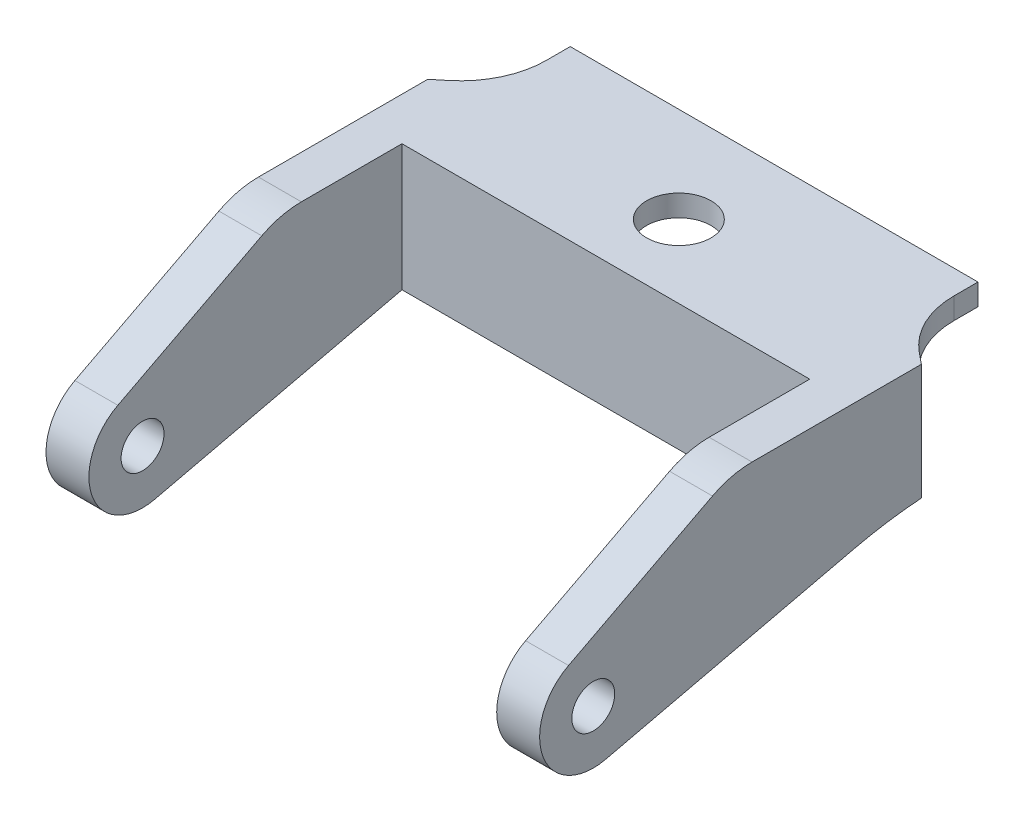
from build123d import *

# Parameters (mm, degrees)
EXTRUDE_1_DEPTH          = 20
EXTRUDE_1_DEPTH_BACK     = 5
EXTRUDE_2_DEPTH          = 5.5
SKETCH_1_5_R             = 1.5
CUT_EXTRUDE_1_DEPTH      = 4.5
CUT_EXTRUDE_1_DEPTH_BACK = 2
SKETCH_3_R               = 1
CUT_EXTRUDE_2_DEPTH      = 100
FILLET_3_R               = 20
FILLET_8_R               = 4


with BuildPart() as part:
    # 草图1 → 凸台-拉伸1 (new body, two sides)
    with BuildSketch(Plane(origin=(0, 0, 0), x_dir=(1, 0, 0), z_dir=(0, 1, 0))) as extrude_1_sk:
        with BuildLine():
            Line((0, -51.852813742), (0, -52.252813742))
            Line((0, -52.252813742), (9.5, -52.252813742))
            Line((9.5, -52.252813742), (9.5, -70.252813742))
            Line((9.5, -70.252813742), (11.5, -70.252813742))
            Line((11.5, -70.252813742), (11.5, -49.052813742))
            Line((11.5, -49.052813742), (9.5, -47.413831048))
            Line((9.5, -47.413831048), (9.5, -44.41312259))
            Line((9.5, -44.41312259), (0, -44.41312259))
            Line((0, -44.41312259), (0, -47.352813742))
            ThreePointArc((0, -47.352813742), (1.5, -48.852813742), (0, -50.352813742))
            Line((0, -50.352813742), (0, -51.852813742))
        make_face()
    extrude(amount=EXTRUDE_1_DEPTH)
    extrude(extrude_1_sk.sketch, amount=-EXTRUDE_1_DEPTH_BACK)

    # 草图1<7> → 凸台-拉伸2 (add)
    with BuildSketch(Plane(origin=(0, 0, 0), x_dir=(1, 0, 0), z_dir=(0, 1, 0))):
        with BuildLine():
            Line((0, -50.352813742), (0, -51.852813742))
            ThreePointArc((0, -51.852813742), (2.274628745, -50.808846481), (2.966165528, -48.403523125))
            Line((2.966165528, -48.403523125), (9.5, -47.413831048))
            Line((9.5, -47.413831048), (9.5, -44.41312259))
            Line((9.5, -44.41312259), (0, -44.41312259))
            Line((0, -44.41312259), (0, -47.352813742))
            ThreePointArc((0, -47.352813742), (1.5, -48.852813742), (0, -50.352813742))
        make_face()
    extrude(amount=EXTRUDE_2_DEPTH)

    # 草图1<5> → 切除-拉伸1 (cut, two sides)
    with BuildSketch(Plane(origin=(0, 0, 0), x_dir=(1, 0, 0), z_dir=(0, 1, 0))) as cut_extrude_1_sk:
        with BuildLine():
            Line((0, -50.352813742), (0, -51.852813742))
            ThreePointArc((0, -51.852813742), (2.274628745, -50.808846481), (2.966165528, -48.403523125))
            Line((2.966165528, -48.403523125), (9.5, -47.413831048))
            Line((9.5, -47.413831048), (9.5, -44.41312259))
            Line((9.5, -44.41312259), (0, -44.41312259))
            Line((0, -44.41312259), (0, -47.352813742))
            ThreePointArc((0, -47.352813742), (1.5, -48.852813742), (0, -50.352813742))
        make_face()
        with BuildLine():
            Line((0, -26.352813742), (0, -29.352813742))
            Line((0, -29.352813742), (10, -29.352813742))
            ThreePointArc((10, -29.352813742), (12.121320344, -24.231493399), (7, -26.352813742))
            Line((7, -26.352813742), (0, -26.352813742))
        make_face()
        with Locations((10, -26.352813742)):
            Circle(SKETCH_1_5_R, mode=Mode.SUBTRACT)
    extrude(amount=CUT_EXTRUDE_1_DEPTH, mode=Mode.SUBTRACT)
    extrude(cut_extrude_1_sk.sketch, amount=-CUT_EXTRUDE_1_DEPTH_BACK, mode=Mode.SUBTRACT)

    # 草图3 → 切除-拉伸2 (cut)
    with BuildSketch(Plane(origin=(11.5, 0, 0), x_dir=(0, 0, -1), z_dir=(1, 0, 0))):
        with BuildLine():
            Line((-57.918477605, 5.5), (-42.203980761, 5.5))
            Line((-42.203980761, 5.5), (-40.897963641, 24.166318072))
            Line((-40.897963641, 24.166318072), (-83.266559668, 28.095474909))
            Line((-83.266559668, 28.095474909), (-85.239587029, -9.794237843))
            Line((-85.239587029, -9.794237843), (-43.684715074, -5.18920723))
            Line((-43.684715074, -5.18920723), (-42.964099773, 0.151496704))
            Line((-42.964099773, 0.151496704), (-49.918517235, 0.151496704))
            Line((-49.918517235, 0.151496704), (-63.77029754, -3.087900575))
            ThreePointArc((-63.77029754, -3.087900575), (-66.684209706, -1.521268022), (-65.492240114, 1.56489953))
            Line((-65.492240114, 1.56489953), (-57.918477605, 5.5))
        make_face()
        with Locations((-64.339596777, -0.653556379)):
            Circle(SKETCH_3_R)
    extrude(amount=-CUT_EXTRUDE_2_DEPTH, mode=Mode.SUBTRACT)

    # 圆角3
    fillet_3_edges = [part.edges().sort_by_distance(p)[0] for p in [
        (7.152165831, 0.151496704, 49.918517235),
    ]]
    fillet(fillet_3_edges, radius=FILLET_3_R)

    # 圆角8
    fillet_8_edges = [part.edges().sort_by_distance(p)[0] for p in [
        (2.966165528, 2.317894753, 48.403523125),
        (9.5, 5, 47.413831048),
        (10.5, 5.5, 57.918477605),
    ]]
    fillet(fillet_8_edges, radius=FILLET_8_R)

    # 镜向1: part across plane


with BuildPart() as part_1:
    add(part.part)
    add(part.part.mirror(Plane(origin=(0, -5, 0), x_dir=(0, 0, 1), z_dir=(1, 0, 0))))


solid = part_1.part
